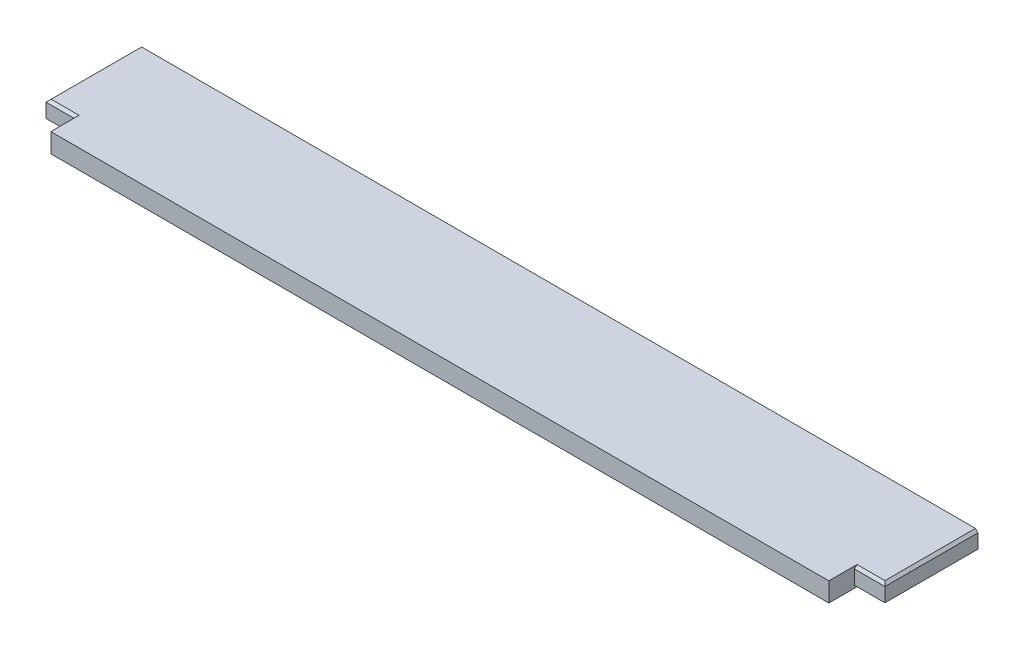
from build123d import *

# Parameters (mm, degrees)
BOSS_EXTRUDE1_DEPTH = 19.05
CHAMFER1_SIZE       = 2.54


with BuildPart() as part:
    # Sketch1 → Boss-Extrude1 (new body)
    with BuildSketch(Plane(origin=(0, 0, 0), x_dir=(1, 0, 0), z_dir=(0, 1, 0))):
        Polygon((30.1625, 0), (800.1127, 0), (800.1127, 25.4), (830.2752, 25.4), (830.2752, 117.475), (0, 117.475), (0, 25.4), (30.1625, 25.4), align=None)
    extrude(amount=BOSS_EXTRUDE1_DEPTH)

    # Chamfer1
    chamfer1_edges = [part.edges().sort_by_distance(p)[0] for p in [
        (15.08125, 0, -25.4),
        (0, 0, -71.4375),
        (830.2752, 0, -71.4375),
        (0, 19.05, -71.4375),
        (15.08125, 19.05, -25.4),
        (815.19395, 19.05, -25.4),
        (830.2752, 19.05, -71.4375),
        (815.19395, 0, -25.4),
    ]]
    chamfer(chamfer1_edges, length=CHAMFER1_SIZE)


solid = part.part
